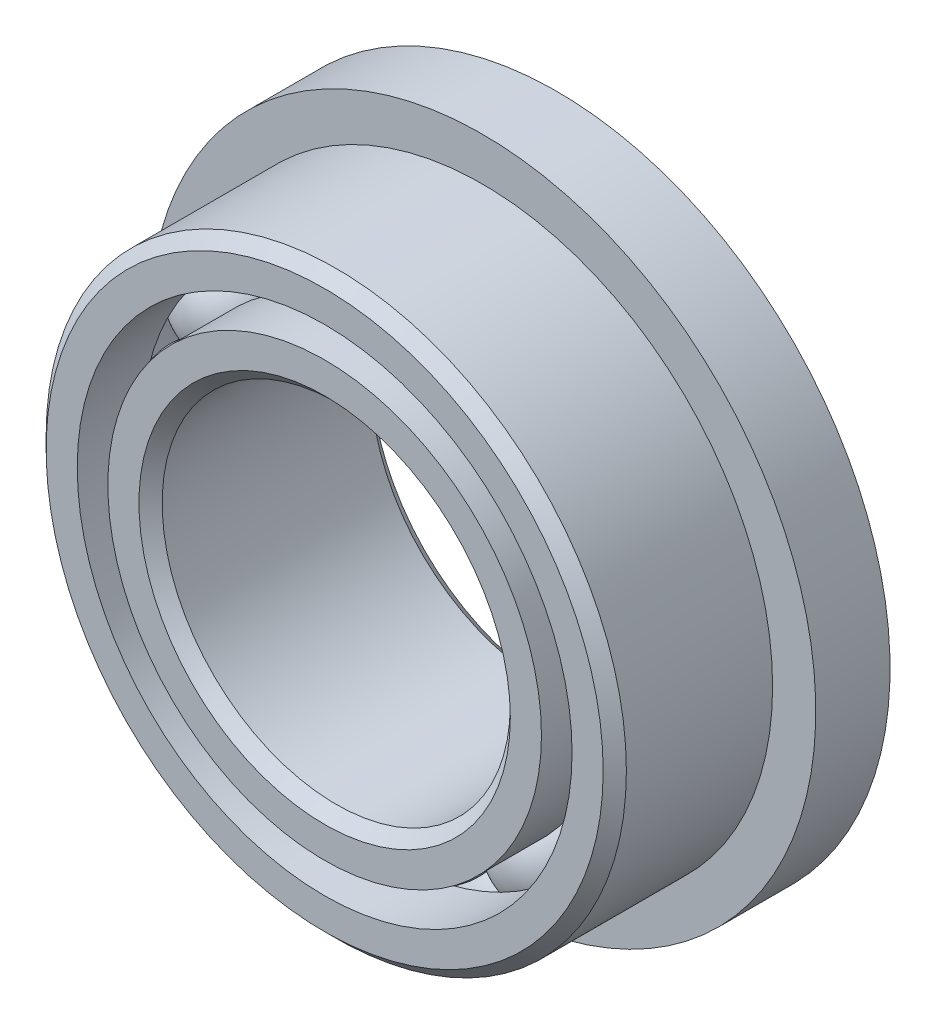
from build123d import *

# Parameters (mm, degrees)
SKETCH5_W         = 1.016
SKETCH5_H         = 0.96212967
CIRPATTERN1_COUNT = 12


with BuildPart() as part:
    # Sketch1 → Revolve1 (revolve)
    with BuildSketch(Plane(origin=(0, 0, 0), x_dir=(0, 0, -1), z_dir=(1, 0, 0))):
        with BuildLine():
            Line((1.42875, 3.96875), (-1.42875, 3.96875))
            Line((-1.42875, 3.96875), (-1.5875, 3.81))
            Line((-1.5875, 3.81), (-1.5875, 3.384340659))
            Line((-1.5875, 3.384340659), (-0.705555556, 3.384340659))
            ThreePointArc((-0.705555556, 3.384340659), (0, 3.910956625), (0.705555556, 3.384340659))
            Line((0.705555556, 3.384340659), (1.5875, 3.384340659))
            Line((1.5875, 3.384340659), (1.5875, 3.81))
            Line((1.5875, 3.81), (1.42875, 3.96875))
        make_face()
    revolve(axis=Axis((0, 0, 1.5875), (0, 0, -1)))

    # Sketch5 → Revolve5 (revolve)
    with BuildSketch(Plane(origin=(0, 0, 0), x_dir=(0, 0, -1), z_dir=(1, 0, 0))):
        with Locations((1.0795, 4.078235165)):
            Rectangle(SKETCH5_W, SKETCH5_H)
    revolve(axis=Axis((0, 0, -1.5875), (0, 0, 1)))


with BuildPart() as body_2:
    # Sketch3 → Revolve3 (revolve)
    with BuildSketch(Plane(origin=(0, 0, 0), x_dir=(0, 0, -1), z_dir=(1, 0, 0))):
        with BuildLine():
            Line((-0.705555556, 2.965659341), (-1.5875, 2.965659341))
            Line((-1.5875, 2.965659341), (-1.5875, 2.54))
            Line((-1.5875, 2.54), (-1.42875, 2.38125))
            Line((-1.42875, 2.38125), (1.42875, 2.38125))
            Line((1.42875, 2.38125), (1.5875, 2.54))
            Line((1.5875, 2.54), (1.5875, 2.965659341))
            Line((1.5875, 2.965659341), (0.705555556, 2.965659341))
            ThreePointArc((0.705555556, 2.965659341), (0, 2.439043375), (-0.705555556, 2.965659341))
        make_face()
    revolve(axis=Axis((0, 0, 1.5875), (0, 0, -1)))


with BuildPart() as body_3:
    # Sketch4 → Revolve4 (revolve)
    with BuildSketch(Plane(origin=(0, 0, 0), x_dir=(0, 0, -1), z_dir=(1, 0, 0))):
        with BuildLine():
            Line((-0.735956625, 3.175), (0.735956625, 3.175))
            ThreePointArc((0.735956625, 3.175), (0, 3.910956625), (-0.735956625, 3.175))
        make_face()
    revolve(axis=Axis((0, 3.175, 0.735956625), (0, 0, -1)))


with BuildPart() as cirpattern1_1:
    # CirPattern1: pattern copy
    add(body_3.part.rotate(Axis((0, 0, -1.5875), (0, 0, 1)), 1 * 360 / CIRPATTERN1_COUNT))


with BuildPart() as cirpattern1_2:
    # CirPattern1: pattern copy
    add(body_3.part.rotate(Axis((0, 0, -1.5875), (0, 0, 1)), 2 * 360 / CIRPATTERN1_COUNT))


with BuildPart() as cirpattern1_3:
    # CirPattern1: pattern copy
    add(body_3.part.rotate(Axis((0, 0, -1.5875), (0, 0, 1)), 3 * 360 / CIRPATTERN1_COUNT))


with BuildPart() as cirpattern1_4:
    # CirPattern1: pattern copy
    add(body_3.part.rotate(Axis((0, 0, -1.5875), (0, 0, 1)), 4 * 360 / CIRPATTERN1_COUNT))


with BuildPart() as cirpattern1_5:
    # CirPattern1: pattern copy
    add(body_3.part.rotate(Axis((0, 0, -1.5875), (0, 0, 1)), 5 * 360 / CIRPATTERN1_COUNT))


with BuildPart() as cirpattern1_6:
    # CirPattern1: pattern copy
    add(body_3.part.rotate(Axis((0, 0, -1.5875), (0, 0, 1)), 6 * 360 / CIRPATTERN1_COUNT))


with BuildPart() as cirpattern1_7:
    # CirPattern1: pattern copy
    add(body_3.part.rotate(Axis((0, 0, -1.5875), (0, 0, 1)), 7 * 360 / CIRPATTERN1_COUNT))


with BuildPart() as cirpattern1_8:
    # CirPattern1: pattern copy
    add(body_3.part.rotate(Axis((0, 0, -1.5875), (0, 0, 1)), 8 * 360 / CIRPATTERN1_COUNT))


with BuildPart() as cirpattern1_9:
    # CirPattern1: pattern copy
    add(body_3.part.rotate(Axis((0, 0, -1.5875), (0, 0, 1)), 9 * 360 / CIRPATTERN1_COUNT))


with BuildPart() as cirpattern1_10:
    # CirPattern1: pattern copy
    add(body_3.part.rotate(Axis((0, 0, -1.5875), (0, 0, 1)), 10 * 360 / CIRPATTERN1_COUNT))


with BuildPart() as cirpattern1_11:
    # CirPattern1: pattern copy
    add(body_3.part.rotate(Axis((0, 0, -1.5875), (0, 0, 1)), 11 * 360 / CIRPATTERN1_COUNT))


solid = Compound([part.part, body_2.part, body_3.part, cirpattern1_1.part, cirpattern1_2.part, cirpattern1_3.part, cirpattern1_4.part, cirpattern1_5.part, cirpattern1_6.part, cirpattern1_7.part, cirpattern1_8.part, cirpattern1_9.part, cirpattern1_10.part, cirpattern1_11.part])
